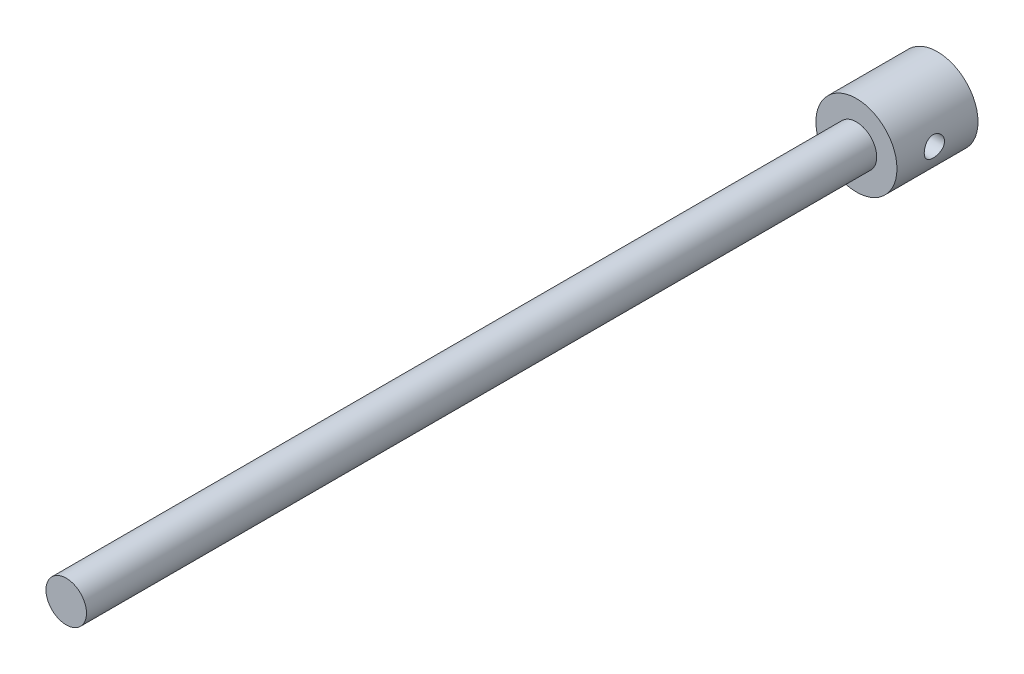
from build123d import *

# Parameters (mm, degrees)
SKETCH1_R               = 25.4
EXTRUDE1_DEPTH          = 50.8
SKETCH2_R               = 12.7
EXTRUDE2_DEPTH          = 495.3
SKETCH3_R               = 6.35
CUT_EXTRUDE1_DEPTH      = 26.4
CUT_EXTRUDE1_DEPTH_BACK = 26.4


with BuildPart() as part:
    # Sketch1 → Extrude1 (new body)
    with BuildSketch(Plane.XY):
        Circle(SKETCH1_R)
    extrude(amount=EXTRUDE1_DEPTH)

    # Sketch2 → Extrude2 (add)
    with BuildSketch(Plane.XY.offset(50.8)):
        Circle(SKETCH2_R)
    extrude(amount=EXTRUDE2_DEPTH)

    # Sketch3 → Cut-Extrude1 (cut, two sides)
    with BuildSketch(Plane(origin=(0, 0, 0), x_dir=(0, 0, -1), z_dir=(1, 0, 0))) as cut_extrude1_sk:
        with Locations((-27.347285404, 0)):
            Circle(SKETCH3_R)
    extrude(amount=CUT_EXTRUDE1_DEPTH, mode=Mode.SUBTRACT)
    extrude(cut_extrude1_sk.sketch, amount=-CUT_EXTRUDE1_DEPTH_BACK, mode=Mode.SUBTRACT)


solid = part.part
